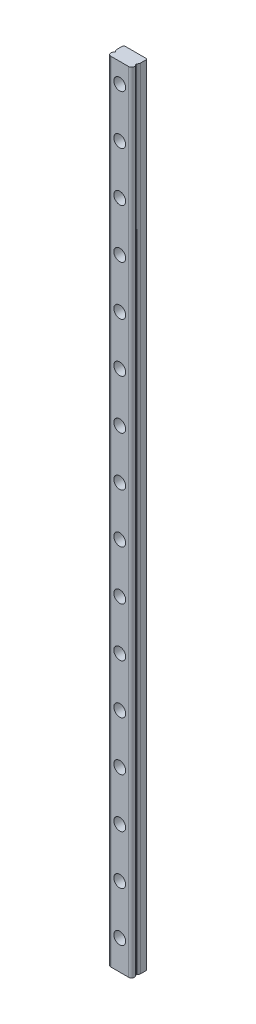
from build123d import *

# Parameters (mm, degrees)
SKETCH1_W           = 12
SKETCH1_H           = 400
BOSS_EXTRUDE1_DEPTH = 8
CUT_EXTRUDE1_DEPTH  = 401
SKETCH3_R           = 3
CUT_EXTRUDE2_DEPTH  = 4.5
SKETCH4_R           = 1.75
CUT_EXTRUDE3_DEPTH  = 4.5
LPATTERN1_COUNT     = 16
LPATTERN1_PITCH     = 25


with BuildPart() as part:
    # Sketch1 → Boss-Extrude1 (new body)
    with BuildSketch(Plane.XY):
        with Locations((0, 200)):
            Rectangle(SKETCH1_W, SKETCH1_H)
    extrude(amount=BOSS_EXTRUDE1_DEPTH)

    # Sketch2 → Cut-Extrude1 (cut, through all)
    with BuildSketch(Plane(origin=(0, 400, 0), x_dir=(1, 0, 0), z_dir=(0, 1, 0))):
        with BuildLine():
            Line((-5.5, 0), (-6, -0.5))
            Line((-6, -0.5), (-6, -3.5))
            ThreePointArc((-6, -3.5), (-5.867156742, -4.117156742), (-5.492156742, -4.625))
            ThreePointArc((-5.492156742, -4.625), (-5.322875656, -5), (-5.492156742, -5.375))
            ThreePointArc((-5.492156742, -5.375), (-5.90312152, -7.030330086), (-4.5, -8))
            Line((-4.5, -8), (-7.760322007, -8))
            Line((-7.760322007, -8), (-7.760322007, 0))
            Line((-7.760322007, 0), (-5.5, 0))
        make_face()
        with BuildLine():
            Line((6, -0.5), (6, -3.5))
            ThreePointArc((6, -3.5), (5.867156742, -4.117156742), (5.492156742, -4.625))
            ThreePointArc((5.492156742, -4.625), (5.322875656, -5), (5.492156742, -5.375))
            ThreePointArc((5.492156742, -5.375), (5.90312152, -7.030330086), (4.5, -8))
            Line((4.5, -8), (7.760322007, -8))
            Line((7.760322007, -8), (7.760322007, 0))
            Line((7.760322007, 0), (5.5, 0))
            Line((5.5, 0), (6, -0.5))
        make_face()
    extrude(amount=-CUT_EXTRUDE1_DEPTH, mode=Mode.SUBTRACT)

    # Sketch3 → Cut-Extrude2 (cut)
    with BuildSketch(Plane.XY.offset(8)):
        with Locations((0, 390)):
            Circle(SKETCH3_R)
    cut_extrude2 = extrude(amount=-CUT_EXTRUDE2_DEPTH, mode=Mode.SUBTRACT)

    # Sketch4 → Cut-Extrude3 (cut, through all)
    with BuildSketch(Plane.XY.offset(3.5)):
        with Locations((0, 390)):
            Circle(SKETCH4_R)
    cut_extrude3 = extrude(amount=-CUT_EXTRUDE3_DEPTH, mode=Mode.SUBTRACT)

    # LPattern1: Cut-Extrude2, Cut-Extrude3 ×16
    with Locations(*[(0, -i * LPATTERN1_PITCH, 0) for i in range(1, LPATTERN1_COUNT)]):
        add(cut_extrude2, mode=Mode.SUBTRACT)
        add(cut_extrude3, mode=Mode.SUBTRACT)


solid = part.part
